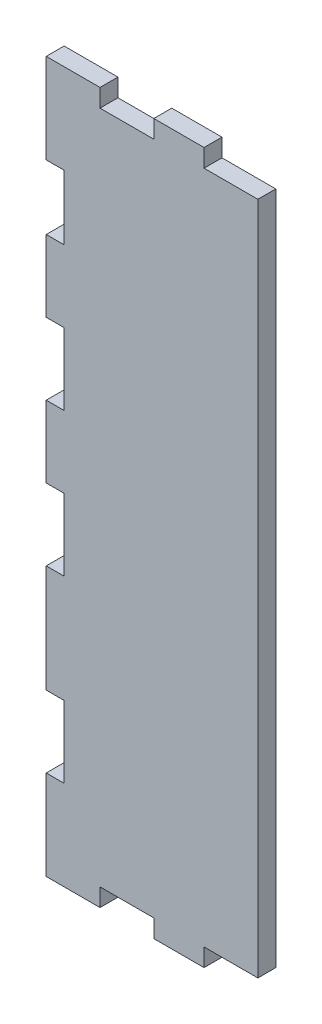
from build123d import *

# Parameters (mm, degrees)
BOSS_EXTRUDE1_DEPTH = 6.35
SKETCH3_W           = 19.05
SKETCH3_H           = 6.35
CUT_EXTRUDE1_DEPTH  = 6.35
SKETCH4_W           = 1.27
SKETCH4_H           = 6.35
CUT_EXTRUDE2_DEPTH  = 252.46
SKETCH5_W           = 19.05
SKETCH5_H           = 6.35
CUT_EXTRUDE3_DEPTH  = 6.35
SKETCH6_W           = 6.35
SKETCH6_H           = 25.4
SKETCH6_H_2         = 22.86
CUT_EXTRUDE4_DEPTH  = 6.35


with BuildPart() as part:
    # Sketch1 → Boss-Extrude1 (new body)
    with BuildSketch(Plane.XY):
        Polygon((0, 1.27), (-69.85, 1.27), (-76.2, 1.27), (-76.2, 252.73), (-69.85, 252.73), (0, 252.73), align=None)
    extrude(amount=BOSS_EXTRUDE1_DEPTH)

    # Sketch3 → Cut-Extrude1 (cut)
    with BuildSketch(Plane(origin=(0, 252.73, 0), x_dir=(1, 0, 0), z_dir=(0, 1, 0))):
        with Locations((-46.355, -3.175)):
            Rectangle(SKETCH3_W, SKETCH3_H)
        with Locations((-9.525, -3.175)):
            Rectangle(SKETCH3_W, SKETCH3_H)
    extrude(amount=-CUT_EXTRUDE1_DEPTH, mode=Mode.SUBTRACT)

    # Sketch4 → Cut-Extrude2 (cut, through all)
    with BuildSketch(Plane(origin=(0, 252.73, 0), x_dir=(1, 0, 0), z_dir=(0, 1, 0))):
        with Locations((-75.565, -3.175)):
            Rectangle(SKETCH4_W, SKETCH4_H)
    extrude(amount=-CUT_EXTRUDE2_DEPTH, mode=Mode.SUBTRACT)

    # Sketch5 → Cut-Extrude3 (cut)
    with BuildSketch(Plane.XZ.offset(-1.27)):
        with Locations((-46.355, 3.175)):
            Rectangle(SKETCH5_W, SKETCH5_H)
        with Locations((-9.525, 3.175)):
            Rectangle(SKETCH5_W, SKETCH5_H)
    extrude(amount=-CUT_EXTRUDE3_DEPTH, mode=Mode.SUBTRACT)

    # Sketch6 → Cut-Extrude4 (cut)
    with BuildSketch(Plane.XY.offset(6.35)):
        with Locations((-71.755, 45.72)):
            Rectangle(SKETCH6_W, SKETCH6_H)
        with Locations((-71.755, 109.22)):
            Rectangle(SKETCH6_W, SKETCH6_H)
        with Locations((-71.755, 160.02)):
            Rectangle(SKETCH6_W, SKETCH6_H)
        with Locations((-71.755, 209.55)):
            Rectangle(SKETCH6_W, SKETCH6_H_2)
    extrude(amount=-CUT_EXTRUDE4_DEPTH, mode=Mode.SUBTRACT)


solid = part.part
